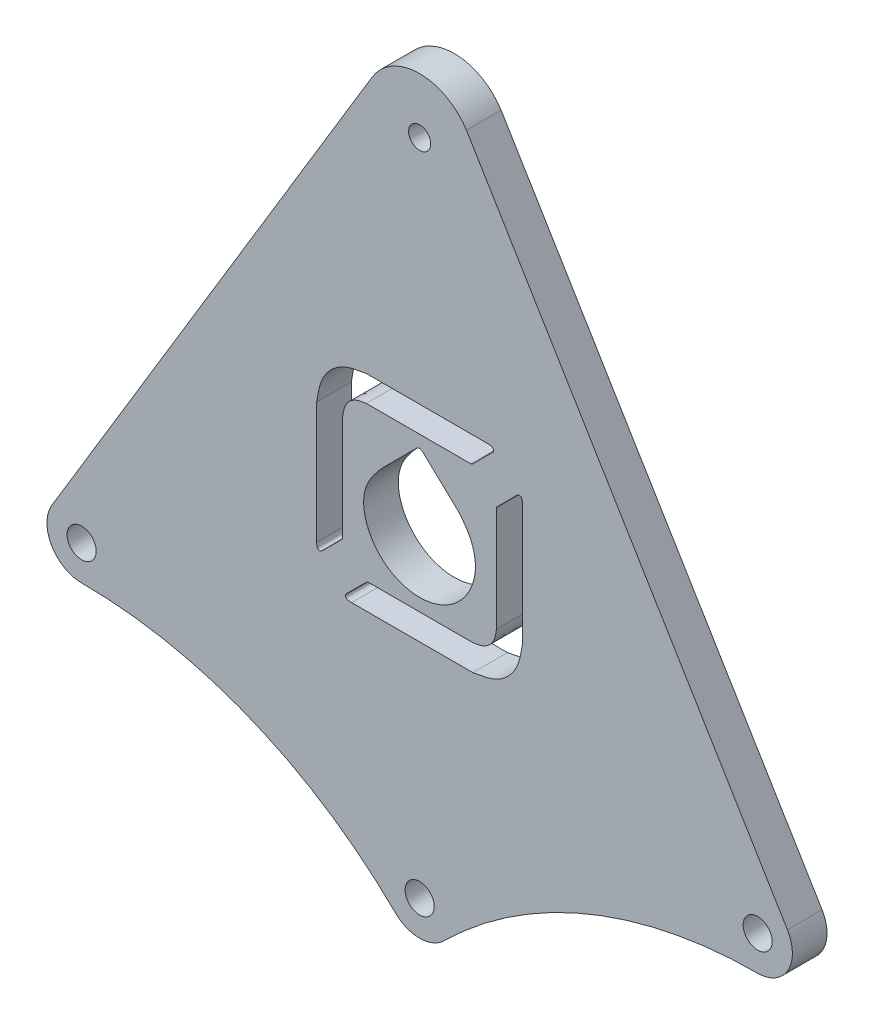
from build123d import *

# Parameters (mm, degrees)
SKETCH1_R           = 2.1
SKETCH1_R_2         = 1.6
BOSS_EXTRUDE1_DEPTH = 5
CUT_EXTRUDE1_DEPTH  = 6


with BuildPart() as part:
    # Sketch1 → Boss-Extrude1 (new body)
    with BuildSketch(Plane.XY):
        with BuildLine():
            Line((-6.849997051, 99.132498083), (-53.031248157, 22.582811302))
            ThreePointArc((-53.031248157, 22.582811302), (-53.103966956, 17.541754336), (-48.75, 15))
            ThreePointArc((-48.75, 15), (-24.301233146, 10.179806707), (-3.511536297, -3.559369724))
            ThreePointArc((-3.511536297, -3.559369724), (0, -5), (3.511536297, -3.559369724))
            ThreePointArc((3.511536297, -3.559369724), (24.301233146, 10.179806707), (48.75, 15))
            ThreePointArc((48.75, 15), (53.104000381, 17.541813538), (53.031177917, 22.582927727))
            Line((53.031177917, 22.582927727), (6.745924993, 99.300290221))
            ThreePointArc((6.745924993, 99.300290221), (-0.098723344, 102.999390833), (-6.849997051, 99.132498083))
        make_face()
        Circle(SKETCH1_R, mode=Mode.SUBTRACT)
        with Locations((-48.75, 20)):
            Circle(SKETCH1_R, mode=Mode.SUBTRACT)
        with Locations((48.75, 20)):
            Circle(SKETCH1_R, mode=Mode.SUBTRACT)
        with Locations((0, 95)):
            Circle(SKETCH1_R_2, mode=Mode.SUBTRACT)
    extrude(amount=BOSS_EXTRUDE1_DEPTH)

    # Sketch2 → Cut-Extrude1 (cut, through all)
    with BuildSketch(Plane.XY.offset(5)):
        with BuildLine():
            Line((-0.443864112, 55.984334269), (-5.297300405, 51.131179975))
            add(Edge.make_bspline(
                [(-5.297300405, 51.131179975), (-5.301766748, 51.127009417), (-5.310511324, 51.11884395), (-5.322913657, 51.106378091), (-5.78139226, 50.600055571), (-6.674828376, 49.554708202), (-7.775003562, 47.750327569), (-8.332785357, 44.927376908), (-7.290519819, 41.392117491), (-4.222914485, 38.330100966), (-0.002965829, 37.186656905), (4.213976272, 38.327822015), (7.269010111, 41.396137842), (8.277646634, 44.91662707), (7.767067878, 47.711666533), (6.853177127, 49.585300342), (5.979525982, 50.62775004), (5.557613885, 51.131179975)],
                knots=[0, 0, 0, 0, 0.000489092, 0.000957584, 0.001406885, 0.055155152, 0.111026991, 0.168427122, 0.280644353, 0.389809521, 0.502189722, 0.614354085, 0.723170681, 0.835316449, 0.891384032, 0.947546121, 1, 1, 1, 1], degree=3))
            Line((5.557613885, 51.131179975), (0.407774184, 55.984334269))
            add(Edge.make_bspline(
                [(0.407774184, 55.984334269), (0.368639039, 56.01821007), (0.291291772, 56.085162693), (0.15156375, 56.154427348), (0.050487127, 56.164249031), (0, 56.169154899)],
                knots=[0, 0, 0, 0, 0.338885039, 0.6697773, 1, 1, 1, 1], degree=3))
            add(Edge.make_bspline(
                [(0, 56.169154899), (-0.052633639, 56.164068541), (-0.161028147, 56.153593619), (-0.315260563, 56.089795141), (-0.401221102, 56.019303514), (-0.443864112, 55.984334269)],
                knots=[0, 0, 0, 0, 0.322338023, 0.663827768, 1, 1, 1, 1], degree=3))
        make_face()
        with BuildLine():
            Line((-7.706098588, 57.951066335), (7.372618255, 57.951066335))
            add(Edge.make_bspline(
                [(7.372618255, 57.951066335), (7.394754066, 57.952741312), (7.438148671, 57.956024902), (7.503316982, 57.963704879), (7.552503443, 57.989714726), (7.588483352, 58.015170692), (7.61178612, 58.0385611), (7.626086156, 58.053677663), (7.633071734, 58.061062115)],
                knots=[0, 0, 0, 0, 0.227492727, 0.445972237, 0.663373124, 0.787115425, 0.896005733, 1, 1, 1, 1], degree=3))
            Line((7.633071734, 58.061062115), (10.56002888, 60.988126261))
            add(Edge.make_bspline(
                [(10.56002888, 60.988126261), (10.588999398, 61.027414909), (10.647007319, 61.10608291), (10.671026663, 61.254274887), (10.643787951, 61.390199535), (10.576478759, 61.499703932), (10.486018248, 61.5786062), (10.353042857, 61.627990259), (10.192907602, 61.66028096), (10.007800719, 61.693592153), (9.877454096, 61.691038249), (9.80613809, 61.692556472), (9.793770576, 61.693180835), (9.785537684, 61.692596549), (9.781413437, 61.692303853)],
                knots=[0, 0, 0, 0, 0.104345134, 0.208931166, 0.313565445, 0.39799532, 0.482811187, 0.567894079, 0.701186565, 0.836715425, 0.973246641, 0.982162759, 0.991064478, 1, 1, 1, 1], degree=3))
            Line((9.781413437, 61.692303853), (-7.706098588, 61.692303853))
            add(Edge.make_bspline(
                [(-7.706098588, 61.692303853), (-8.954977035, 61.492774456), (-11.421020812, 61.098782367), (-14.261566727, 58.258297615), (-14.655543049, 55.791950747), (-14.85508629, 54.542782152)],
                knots=[0, 0, 0, 0, 0.336153842, 0.663771636, 1, 1, 1, 1], degree=3))
            Line((-14.85508629, 54.542782152), (-14.853675293, 37.055657126))
            add(Edge.make_bspline(
                [(-14.853675293, 37.055657126), (-14.853969375, 37.051675577), (-14.854550282, 37.04381073), (-14.853925359, 37.031949208), (-14.852358667, 36.960744234), (-14.855397231, 36.830160388), (-14.821608172, 36.644666062), (-14.791815493, 36.483796567), (-14.740306085, 36.351730946), (-14.661648646, 36.261445912), (-14.552461758, 36.193440165), (-14.416220728, 36.16617992), (-14.267691647, 36.190514979), (-14.188904909, 36.249229068), (-14.149498701, 36.27859568)],
                knots=[0, 0, 0, 0, 0.008621864, 0.017030969, 0.025643238, 0.162638148, 0.298245388, 0.431901383, 0.516391776, 0.601007159, 0.685956809, 0.790142009, 0.895036806, 1, 1, 1, 1], degree=3))
            Line((-14.149498701, 36.27859568), (-11.223921552, 39.205516826))
            add(Edge.make_bspline(
                [(-11.223921552, 39.205516826), (-11.214976838, 39.214780106), (-11.197424054, 39.232958029), (-11.170226536, 39.259966444), (-11.141538222, 39.295516864), (-11.121606315, 39.344610277), (-11.112021748, 39.403868417), (-11.112299367, 39.44372384), (-11.112443775, 39.464455309)],
                knots=[0, 0, 0, 0, 0.131285455, 0.257629811, 0.390972346, 0.594165008, 0.788898108, 1, 1, 1, 1], degree=3))
            Line((-11.112443775, 39.464455309), (-11.113854772, 54.542782152))
            add(Edge.make_bspline(
                [(-11.113854772, 54.542782152), (-11.025624037, 55.146716493), (-10.853184798, 56.327053242), (-9.491198067, 57.690108032), (-8.310427507, 57.862721315), (-7.706098588, 57.951066335)],
                knots=[0, 0, 0, 0, 0.338409749, 0.6613922, 1, 1, 1, 1], degree=3))
        make_face()
        with BuildLine():
            Line((7.67000866, 35.756025725), (-7.408318183, 35.756025725))
            add(Edge.make_bspline(
                [(-7.408318183, 35.756025725), (-7.427440936, 35.755294528), (-7.462587587, 35.753950624), (-7.516551065, 35.745516006), (-7.560850786, 35.725170186), (-7.600833788, 35.701425624), (-7.635315717, 35.675409267), (-7.657296392, 35.655135089), (-7.668774662, 35.644547948)],
                knots=[0, 0, 0, 0, 0.196745559, 0.361608386, 0.557261599, 0.692766378, 0.839563136, 1, 1, 1, 1], degree=3))
            Line((-7.668774662, 35.644547948), (-10.595729808, 32.717601802))
            add(Edge.make_bspline(
                [(-10.595729808, 32.717601802), (-10.624701104, 32.678293593), (-10.682693852, 32.599609121), (-10.706716869, 32.451443699), (-10.679538616, 32.315457358), (-10.611911158, 32.206024605), (-10.521503266, 32.127364297), (-10.389015109, 32.077411838), (-10.228910201, 32.044860654), (-10.043857278, 32.014590067), (-9.91330711, 32.009088715), (-9.841970676, 32.014306551), (-9.829509786, 32.013673376), (-9.8212444, 32.01350587), (-9.817116366, 32.013422211)],
                knots=[0, 0, 0, 0, 0.104384754, 0.208950226, 0.313569176, 0.398093487, 0.483012464, 0.567612364, 0.700915154, 0.836484685, 0.973043492, 0.982112009, 0.991066088, 1, 1, 1, 1], degree=3))
            Line((-9.817116366, 32.013422211), (7.67000866, 32.013422211))
            add(Edge.make_bspline(
                [(7.67000866, 32.013422211), (8.919019337, 32.213074659), (11.385431011, 32.607326795), (14.226516148, 35.448132826), (14.620076355, 37.914907651), (14.819389361, 39.164170909)],
                knots=[0, 0, 0, 0, 0.336156644, 0.663805911, 1, 1, 1, 1], degree=3))
            Line((14.819389361, 39.164170909), (14.817978364, 56.649953937))
            add(Edge.make_bspline(
                [(14.817978364, 56.649953937), (14.818270541, 56.654088186), (14.818856191, 56.662375028), (14.818228473, 56.674871586), (14.816744384, 56.746304358), (14.819286158, 56.876724441), (14.785908468, 57.061771429), (14.754075315, 57.221842187), (14.70406878, 57.354343023), (14.625479493, 57.444759405), (14.516043168, 57.512357705), (14.380018503, 57.539552733), (14.231550654, 57.515207627), (14.153067034, 57.456521815), (14.113797772, 57.427158383)],
                knots=[0, 0, 0, 0, 0.008953482, 0.017946692, 0.027021307, 0.163490993, 0.298949058, 0.432165007, 0.516776033, 0.601601228, 0.686034701, 0.790672378, 0.895262972, 1, 1, 1, 1], degree=3))
            Line((14.113797772, 57.427158383), (11.186877626, 54.500200237))
            add(Edge.make_bspline(
                [(11.186877626, 54.500200237), (11.177288202, 54.491001836), (11.158411099, 54.472894475), (11.129846255, 54.44509123), (11.099398849, 54.41184917), (11.082600471, 54.362398312), (11.077979491, 54.303834841), (11.077192377, 54.262984189), (11.076773846, 54.241262755)],
                knots=[0, 0, 0, 0, 0.134581529, 0.264928249, 0.404990742, 0.58604785, 0.779890073, 1, 1, 1, 1], degree=3))
            Line((11.076773846, 54.241262755), (11.077902844, 39.164170909))
            add(Edge.make_bspline(
                [(11.077902844, 39.164170909), (10.989969683, 38.560079286), (10.818115376, 37.37945816), (9.455283438, 36.016763389), (8.274418515, 35.844299203), (7.67000866, 35.756025725)],
                knots=[0, 0, 0, 0, 0.33840601, 0.661371999, 1, 1, 1, 1], degree=3))
        make_face()
    extrude(amount=-CUT_EXTRUDE1_DEPTH, mode=Mode.SUBTRACT)


solid = part.part
